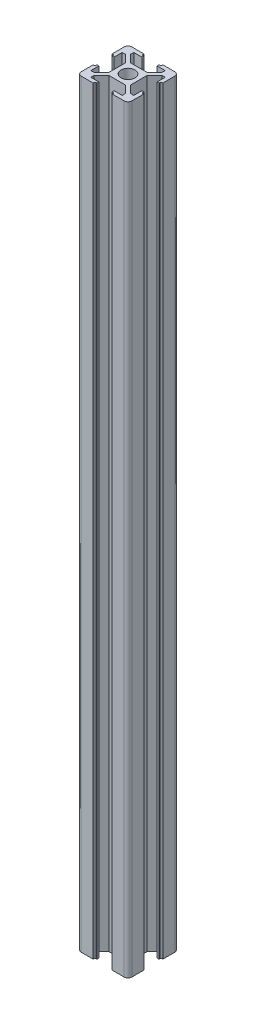
from build123d import *

# Parameters (mm, degrees)
SKETCH1_R           = 2.75
BOSS_EXTRUDE1_DEPTH = 300


with BuildPart() as part:
    # Sketch1 → Boss-Extrude1 (new body)
    with BuildSketch(Plane.XZ):
        with BuildLine():
            Line((-8.5, -10), (-3.75, -10))
            Line((-3.75, -10), (-3.75, -9.65))
            ThreePointArc((-3.75, -9.65), (-3.632842712, -9.367157288), (-3.35, -9.25))
            Line((-3.35, -9.25), (-3, -9.25))
            Line((-3, -9.25), (-3, -8.5))
            Line((-3, -8.5), (-6.2, -8.5))
            Line((-6.2, -8.5), (-6.2, -7.260660172))
            Line((-6.2, -7.260660172), (-3.239339828, -4.3))
            Line((-3.239339828, -4.3), (3.239339828, -4.3))
            Line((3.239339828, -4.3), (6.2, -7.260660172))
            Line((6.2, -7.260660172), (6.2, -8.5))
            Line((6.2, -8.5), (3, -8.5))
            Line((3, -8.5), (3, -9.25))
            Line((3, -9.25), (3.35, -9.25))
            ThreePointArc((3.35, -9.25), (3.632842712, -9.367157288), (3.75, -9.65))
            Line((3.75, -9.65), (3.75, -10))
            Line((3.75, -10), (8.5, -10))
            ThreePointArc((8.5, -10), (9.560660172, -9.560660172), (10, -8.5))
            Line((10, -8.5), (10, -3.75))
            Line((10, -3.75), (9.65, -3.75))
            ThreePointArc((9.65, -3.75), (9.367157288, -3.632842712), (9.25, -3.35))
            Line((9.25, -3.35), (9.25, -3))
            Line((9.25, -3), (8.5, -3))
            Line((8.5, -3), (8.5, -6.2))
            Line((8.5, -6.2), (7.260660172, -6.2))
            Line((7.260660172, -6.2), (4.3, -3.239339828))
            Line((4.3, -3.239339828), (4.3, 3.239339828))
            Line((4.3, 3.239339828), (7.260660172, 6.2))
            Line((7.260660172, 6.2), (8.5, 6.2))
            Line((8.5, 6.2), (8.5, 3))
            Line((8.5, 3), (9.25, 3))
            Line((9.25, 3), (9.25, 3.35))
            ThreePointArc((9.25, 3.35), (9.367157288, 3.632842712), (9.65, 3.75))
            Line((9.65, 3.75), (10, 3.75))
            Line((10, 3.75), (10, 8.5))
            ThreePointArc((10, 8.5), (9.560660172, 9.560660172), (8.5, 10))
            Line((8.5, 10), (3.75, 10))
            Line((3.75, 10), (3.75, 9.65))
            ThreePointArc((3.75, 9.65), (3.632842712, 9.367157288), (3.35, 9.25))
            Line((3.35, 9.25), (3, 9.25))
            Line((3, 9.25), (3, 8.5))
            Line((3, 8.5), (6.2, 8.5))
            Line((6.2, 8.5), (6.2, 7.260660172))
            Line((6.2, 7.260660172), (3.239339828, 4.3))
            Line((3.239339828, 4.3), (-3.239339828, 4.3))
            Line((-3.239339828, 4.3), (-6.2, 7.260660172))
            Line((-6.2, 7.260660172), (-6.2, 8.5))
            Line((-6.2, 8.5), (-3, 8.5))
            Line((-3, 8.5), (-3, 9.25))
            Line((-3, 9.25), (-3.35, 9.25))
            ThreePointArc((-3.35, 9.25), (-3.632842712, 9.367157288), (-3.75, 9.65))
            Line((-3.75, 9.65), (-3.75, 10))
            Line((-3.75, 10), (-8.5, 10))
            ThreePointArc((-8.5, 10), (-9.560660172, 9.560660172), (-10, 8.5))
            Line((-10, 8.5), (-10, 3.75))
            Line((-10, 3.75), (-9.65, 3.75))
            ThreePointArc((-9.65, 3.75), (-9.367157288, 3.632842712), (-9.25, 3.35))
            Line((-9.25, 3.35), (-9.25, 3))
            Line((-9.25, 3), (-8.5, 3))
            Line((-8.5, 3), (-8.5, 6.2))
            Line((-8.5, 6.2), (-7.260660172, 6.2))
            Line((-7.260660172, 6.2), (-4.3, 3.239339828))
            Line((-4.3, 3.239339828), (-4.3, -3.239339828))
            Line((-4.3, -3.239339828), (-7.260660172, -6.2))
            Line((-7.260660172, -6.2), (-8.5, -6.2))
            Line((-8.5, -6.2), (-8.5, -3))
            Line((-8.5, -3), (-9.25, -3))
            Line((-9.25, -3), (-9.25, -3.35))
            ThreePointArc((-9.25, -3.35), (-9.367157288, -3.632842712), (-9.65, -3.75))
            Line((-9.65, -3.75), (-10, -3.75))
            Line((-10, -3.75), (-10, -8.5))
            ThreePointArc((-10, -8.5), (-9.560660172, -9.560660172), (-8.5, -10))
        make_face()
        Circle(SKETCH1_R, mode=Mode.SUBTRACT)
    extrude(amount=-BOSS_EXTRUDE1_DEPTH)


solid = part.part
